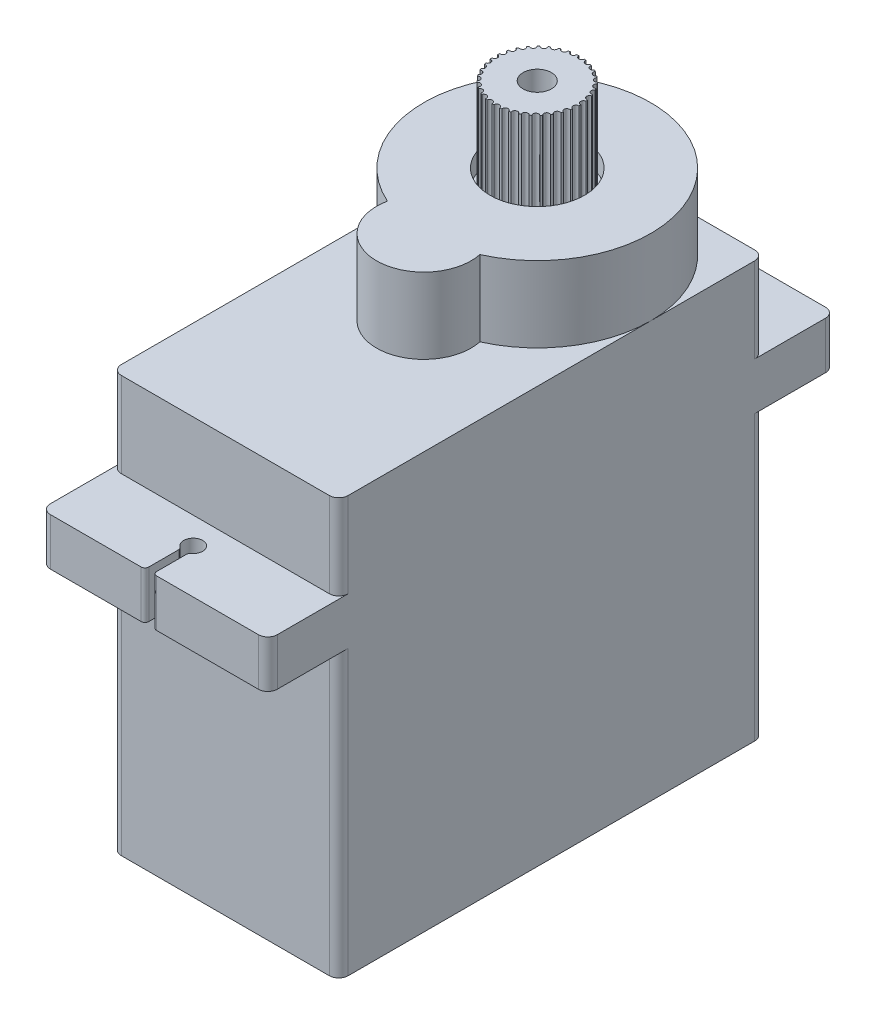
from build123d import *

# Parameters (mm, degrees)
Y_KSEKLIK_EKSTR_ZYON1_DEPTH  = 1
Y_KSEKLIK_EKSTR_ZYON2_DEPTH  = 5
IZIM3_W                      = 4
IZIM3_H                      = 1
KES_EKSTR_ZYON1_DEPTH        = 1
RADYUS1_R                    = 0.1
Y_KSEKLIK_EKSTR_ZYON4_DEPTH  = 9
Y_KSEKLIK_EKSTR_ZYON5_DEPTH  = 2.5
Y_KSEKLIK_EKSTR_ZYON6_DEPTH  = 3.5
Y_KSEKLIK_EKSTR_ZYON7_DEPTH  = 1
KES_EKSTR_ZYON2_DEPTH        = 1
Y_KSEKLIK_EKSTR_ZYON8_START  = 3
Y_KSEKLIK_EKSTR_ZYON8_DEPTH  = 3
RADYUS2_R                    = 0.5
Y_KSEKLIK_EKSTR_ZYON9_START  = 1
Y_KSEKLIK_EKSTR_ZYON9_DEPTH  = 1
IZIM11_R                     = 2.5
KES_EKSTR_ZYON3_DEPTH        = 10
IZIM15_R                     = 0.25
Y_KSEKLIK_EKSTR_ZYON12_DEPTH = 11
IZIM19_R                     = 2.25
Y_KSEKLIK_EKSTR_ZYON17_DEPTH = 5
IZIM20_R                     = 4.75
Y_KSEKLIK_EKSTR_ZYON18_DEPTH = 3
IZIM21_R                     = 0.75
KES_EKSTR_ZYON5_DEPTH        = 10
IZIM22_R                     = 0.5
Y_KSEKLIK_EKSTR_ZYON19_DEPTH = 5
IZIM23_R                     = 4
Y_KSEKLIK_EKSTR_ZYON20_DEPTH = 2
IZIM24_R                     = 0.75
Y_KSEKLIK_EKSTR_ZYON21_DEPTH = 7
IZIM25_R                     = 3.5
Y_KSEKLIK_EKSTR_ZYON22_DEPTH = 1
IZIM26_R                     = 4.5
Y_KSEKLIK_EKSTR_ZYON23_DEPTH = 1
KES_EKSTR_ZYON7_DEPTH        = 30
Y_KSEKLIK_EKSTR_ZYON33_DEPTH = 1
Y_KSEKLIK_EKSTR_ZYON34_DEPTH = 14
IZIM37_W                     = 8
IZIM37_H                     = 6
Y_KSEKLIK_EKSTR_ZYON36_DEPTH = 1
IZIM39_W                     = 4
IZIM39_H                     = 1
Y_KSEKLIK_EKSTR_ZYON37_DEPTH = 0.1
IZIM40_R                     = 0.4
Y_KSEKLIK_EKSTR_ZYON38_DEPTH = 2
IZIM41_R                     = 0.15
KES_EKSTR_ZYON8_DEPTH        = 5


with BuildPart() as part:
    # Çizim1 → Yükseklik-Ekstrüzyon1 (new body)
    with BuildSketch(Plane(origin=(0, 0, 0), x_dir=(1, 0, 0), z_dir=(0, 1, 0))):
        with BuildLine():
            Line((-5.5, 11.25), (5.5, 11.25))
            ThreePointArc((5.5, 11.25), (5.853553391, 11.103553391), (6, 10.75))
            Line((6, 10.75), (6, -10.75))
            ThreePointArc((6, -10.75), (5.853553391, -11.103553391), (5.5, -11.25))
            Line((5.5, -11.25), (-5.5, -11.25))
            ThreePointArc((-5.5, -11.25), (-5.853553391, -11.103553391), (-6, -10.75))
            Line((-6, -10.75), (-6, 10.75))
            ThreePointArc((-6, 10.75), (-5.853553391, 11.103553391), (-5.5, 11.25))
        make_face()
    extrude(amount=Y_KSEKLIK_EKSTR_ZYON1_DEPTH)

    # Çizim2 → Yükseklik-Ekstrüzyon2 (add)
    with BuildSketch(Plane(origin=(0, 1, 0), x_dir=(1, 0, 0), z_dir=(0, 1, 0))):
        with BuildLine():
            Line((-5.5, 11.25), (5.5, 11.25))
            ThreePointArc((5.5, 11.25), (5.853553391, 11.103553391), (6, 10.75))
            Line((6, 10.75), (6, -10.75))
            ThreePointArc((6, -10.75), (5.853553391, -11.103553391), (5.5, -11.25))
            Line((5.5, -11.25), (-5.5, -11.25))
            ThreePointArc((-5.5, -11.25), (-5.853553391, -11.103553391), (-6, -10.75))
            Line((-6, -10.75), (-6, 10.75))
            ThreePointArc((-6, 10.75), (-5.853553391, 11.103553391), (-5.5, 11.25))
        make_face()
        with BuildLine():
            Line((-5, 9.25), (-5, -9.25))
            ThreePointArc((-5, -9.25), (-4.292893219, -9.542893219), (-4, -10.25))
            Line((-4, -10.25), (4, -10.25))
            ThreePointArc((4, -10.25), (4.292893219, -9.542893219), (5, -9.25))
            Line((5, -9.25), (5, 9.25))
            ThreePointArc((5, 9.25), (4.292893219, 9.542893219), (4, 10.25))
            Line((4, 10.25), (-4, 10.25))
            ThreePointArc((-4, 10.25), (-4.292893219, 9.542893219), (-5, 9.25))
        make_face(mode=Mode.SUBTRACT)
    extrude(amount=Y_KSEKLIK_EKSTR_ZYON2_DEPTH)

    # Çizim3 → Kes-Ekstrüzyon1 (cut)
    with BuildSketch(Plane(origin=(0, 6, 0), x_dir=(1, 0, 0), z_dir=(0, 1, 0))):
        with Locations((0, -10.75)):
            Rectangle(IZIM3_W, IZIM3_H)
    extrude(amount=-KES_EKSTR_ZYON1_DEPTH, mode=Mode.SUBTRACT)

    # Radyus1
    radyus1_edges = [part.edges().sort_by_distance(p)[0] for p in [
        (2, 5, 10.75),
        (-2, 5, 10.75),
    ]]
    fillet(radyus1_edges, radius=RADYUS1_R)

    # Çizim4 → Yükseklik-Ekstrüzyon4 (add)
    with BuildSketch(Plane(origin=(0, 6, 0), x_dir=(1, 0, 0), z_dir=(0, 1, 0))):
        with BuildLine():
            Line((5.5, 11.25), (-5.5, 11.25))
            ThreePointArc((-5.5, 11.25), (-5.853553391, 11.103553391), (-6, 10.75))
            Line((-6, 10.75), (-6, -10.75))
            ThreePointArc((-6, -10.75), (-5.853553391, -11.103553391), (-5.5, -11.25))
            Line((-5.5, -11.25), (-2, -11.25))
            Line((-2, -11.25), (2, -11.25))
            Line((2, -11.25), (5.5, -11.25))
            ThreePointArc((5.5, -11.25), (5.853553391, -11.103553391), (6, -10.75))
            Line((6, -10.75), (6, 10.75))
            ThreePointArc((6, 10.75), (5.853553391, 11.103553391), (5.5, 11.25))
        make_face()
        with BuildLine():
            ThreePointArc((-5, 9.25), (-4.292893219, 9.542893219), (-4, 10.25))
            Line((-4, 10.25), (4, 10.25))
            ThreePointArc((4, 10.25), (4.292893219, 9.542893219), (5, 9.25))
            Line((5, 9.25), (5, -9.25))
            ThreePointArc((5, -9.25), (4.292893219, -9.542893219), (4, -10.25))
            Line((4, -10.25), (2, -10.25))
            Line((2, -10.25), (-2, -10.25))
            Line((-2, -10.25), (-4, -10.25))
            ThreePointArc((-4, -10.25), (-4.292893219, -9.542893219), (-5, -9.25))
            Line((-5, -9.25), (-5, 9.25))
        make_face(mode=Mode.SUBTRACT)
    extrude(amount=Y_KSEKLIK_EKSTR_ZYON4_DEPTH)

    # Çizim6 → Yükseklik-Ekstrüzyon5 (add)
    with BuildSketch(Plane(origin=(0, 15, 0), x_dir=(1, 0, 0), z_dir=(0, 1, 0))):
        with BuildLine():
            Line((-5.5, 15), (-0.7, 15))
            ThreePointArc((-0.7, 15), (-0.558578644, 14.941421356), (-0.5, 14.8))
            Line((-0.5, 14.8), (-0.5, 13.224679434))
            ThreePointArc((-0.5, 13.224679434), (-0.522048696, 13.133392342), (-0.583333333, 13.062232862))
            ThreePointArc((-0.583333333, 13.062232862), (-0.291666667, 12.156116431), (0, 13.062232862))
            ThreePointArc((0, 13.062232862), (-0.061284638, 13.133392342), (-0.083333333, 13.224679434))
            Line((-0.083333333, 13.224679434), (-0.083333333, 14.8))
            ThreePointArc((-0.083333333, 14.8), (-0.02475469, 14.941421356), (0.116666667, 15))
            Line((0.116666667, 15), (5.5, 15))
            ThreePointArc((5.5, 15), (5.853553391, 14.853553391), (6, 14.5))
            Line((6, 14.5), (6, -14.5))
            ThreePointArc((6, -14.5), (5.853553391, -14.853553391), (5.5, -15))
            Line((5.5, -15), (0.116666667, -15))
            ThreePointArc((0.116666667, -15), (-0.02475469, -14.941421356), (-0.083333333, -14.8))
            Line((-0.083333333, -14.8), (-0.083333333, -13.224679434))
            ThreePointArc((-0.083333333, -13.224679434), (-0.061284638, -13.133392342), (0, -13.062232862))
            ThreePointArc((0, -13.062232862), (-0.291666667, -12.156116431), (-0.583333333, -13.062232862))
            ThreePointArc((-0.583333333, -13.062232862), (-0.522048696, -13.133392342), (-0.5, -13.224679434))
            Line((-0.5, -13.224679434), (-0.5, -14.8))
            ThreePointArc((-0.5, -14.8), (-0.558578644, -14.941421356), (-0.7, -15))
            Line((-0.7, -15), (-5.5, -15))
            ThreePointArc((-5.5, -15), (-5.853553391, -14.853553391), (-6, -14.5))
            Line((-6, -14.5), (-6, 14.5))
            ThreePointArc((-6, 14.5), (-5.853553391, 14.853553391), (-5.5, 15))
        make_face()
        with BuildLine():
            Line((-4, 10.25), (4, 10.25))
            ThreePointArc((4, 10.25), (4.292893219, 9.542893219), (5, 9.25))
            Line((5, 9.25), (5, -9.25))
            ThreePointArc((5, -9.25), (4.324856337, -9.512313729), (4.003911578, -10.161637931))
            Line((4.003911578, -10.161637931), (-4.003911578, -10.161637931))
            ThreePointArc((-4.003911578, -10.161637931), (-4.324856337, -9.512313729), (-5, -9.25))
            Line((-5, -9.25), (-5, 9.25))
            ThreePointArc((-5, 9.25), (-4.292893219, 9.542893219), (-4, 10.25))
        make_face(mode=Mode.SUBTRACT)
    extrude(amount=Y_KSEKLIK_EKSTR_ZYON5_DEPTH)

    # Çizim7 → Yükseklik-Ekstrüzyon6 (add)
    with BuildSketch(Plane(origin=(0, 17.5, 0), x_dir=(1, 0, 0), z_dir=(0, 1, 0))):
        with BuildLine():
            Line((5.5, 11.25), (-5.5, 11.25))
            ThreePointArc((-5.5, 11.25), (-5.853553391, 11.103553391), (-6, 10.75))
            Line((-6, 10.75), (-6, -10.75))
            ThreePointArc((-6, -10.75), (-5.853553391, -11.103553391), (-5.5, -11.25))
            Line((-5.5, -11.25), (5.5, -11.25))
            ThreePointArc((5.5, -11.25), (5.853553391, -11.103553391), (6, -10.75))
            Line((6, -10.75), (6, 10.75))
            ThreePointArc((6, 10.75), (5.853553391, 11.103553391), (5.5, 11.25))
        make_face()
        with BuildLine():
            Line((-5, -9.25), (-5, 9.25))
            ThreePointArc((-5, 9.25), (-4.292893219, 9.542893219), (-4, 10.25))
            Line((-4, 10.25), (4, 10.25))
            ThreePointArc((4, 10.25), (4.292893219, 9.542893219), (5, 9.25))
            Line((5, 9.25), (5, -9.25))
            ThreePointArc((5, -9.25), (4.324856337, -9.512313729), (4.003911578, -10.161637931))
            ThreePointArc((4.003911578, -10.161637931), (4.000978373, -10.205775698), (4, -10.25))
            Line((4, -10.25), (-4, -10.25))
            ThreePointArc((-4, -10.25), (-4.000978373, -10.205775698), (-4.003911578, -10.161637931))
            ThreePointArc((-4.003911578, -10.161637931), (-4.324856337, -9.512313729), (-5, -9.25))
        make_face(mode=Mode.SUBTRACT)
    extrude(amount=Y_KSEKLIK_EKSTR_ZYON6_DEPTH)

    # Çizim8 → Yükseklik-Ekstrüzyon7 (add)
    with BuildSketch(Plane(origin=(0, 21, 0), x_dir=(1, 0, 0), z_dir=(0, 1, 0))):
        with BuildLine():
            Line((-5.5, 11.25), (5.5, 11.25))
            ThreePointArc((5.5, 11.25), (5.853553391, 11.103553391), (6, 10.75))
            Line((6, 10.75), (6, -10.75))
            ThreePointArc((6, -10.75), (5.853553391, -11.103553391), (5.5, -11.25))
            Line((5.5, -11.25), (-5.5, -11.25))
            ThreePointArc((-5.5, -11.25), (-5.853553391, -11.103553391), (-6, -10.75))
            Line((-6, -10.75), (-6, 10.75))
            ThreePointArc((-6, 10.75), (-5.853553391, 11.103553391), (-5.5, 11.25))
        make_face()
    extrude(amount=Y_KSEKLIK_EKSTR_ZYON7_DEPTH)

    # Çizim9 → Kes-Ekstrüzyon2 (cut)
    with BuildSketch(Plane(origin=(0, 22, 0), x_dir=(1, 0, 0), z_dir=(0, 1, 0))):
        with BuildLine():
            ThreePointArc((1.015291078, 0.354166667), (0, 10.25), (-1.015291078, 0.354166667))
            ThreePointArc((-1.015291078, 0.354166667), (0, -2.25), (1.015291078, 0.354166667))
        make_face()
    extrude(amount=-KES_EKSTR_ZYON2_DEPTH, mode=Mode.SUBTRACT)

    # Çizim9<3> → Yükseklik-Ekstrüzyon8 (add)
    with BuildSketch(Plane(origin=(0, 22, 0), x_dir=(1, 0, 0), z_dir=(0, 1, 0)).offset(Y_KSEKLIK_EKSTR_ZYON8_START)):
        with BuildLine():
            ThreePointArc((2.445144707, -0.229166667), (0, 11.25), (-2.445144707, -0.229166667))
            ThreePointArc((-2.445144707, -0.229166667), (0, -3.25), (2.445144707, -0.229166667))
        make_face()
        with BuildLine():
            ThreePointArc((1.015291078, 0.354166667), (0, 10.25), (-1.015291078, 0.354166667))
            ThreePointArc((-1.015291078, 0.354166667), (0, -2.25), (1.015291078, 0.354166667))
        make_face(mode=Mode.SUBTRACT)
    extrude(amount=-Y_KSEKLIK_EKSTR_ZYON8_DEPTH)

    # Radyus2
    radyus2_edges = [part.edges().sort_by_distance(p)[0] for p in [
        (1.015291078, 23, -0.354166667),
        (-1.015291078, 23, -0.354166667),
    ]]
    fillet(radyus2_edges, radius=RADYUS2_R)

    # Çizim10 → Yükseklik-Ekstrüzyon9 (add)
    with BuildSketch(Plane(origin=(0, 25, 0), x_dir=(1, 0, 0), z_dir=(0, 1, 0)).offset(Y_KSEKLIK_EKSTR_ZYON9_START)):
        with BuildLine():
            ThreePointArc((2.445144707, -0.229166667), (0, 11.25), (-2.445144707, -0.229166667))
            ThreePointArc((-2.445144707, -0.229166667), (0, -3.25), (2.445144707, -0.229166667))
        make_face()
    extrude(amount=-Y_KSEKLIK_EKSTR_ZYON9_DEPTH)

    # Çizim11 → Kes-Ekstrüzyon3 (cut)
    with BuildSketch(Plane(origin=(0, 26, 0), x_dir=(1, 0, 0), z_dir=(0, 1, 0))):
        with Locations((0, 5.25)):
            Circle(IZIM11_R)
    extrude(amount=-KES_EKSTR_ZYON3_DEPTH, mode=Mode.SUBTRACT)

    # Çizim15 → Yükseklik-Ekstrüzyon12 (add)
    with BuildSketch(Plane(origin=(0, 26, 0), x_dir=(1, 0, 0), z_dir=(0, 1, 0))):
        with Locations((0, -0.75)):
            Circle(IZIM15_R)
    extrude(amount=-Y_KSEKLIK_EKSTR_ZYON12_DEPTH)



with BuildPart() as body_2:
    # Çizim19 → Yükseklik-Ekstrüzyon17 (new body)
    with BuildSketch(Plane(origin=(0, 30, 0), x_dir=(1, 0, 0), z_dir=(0, 1, 0))):
        with Locations((0, 5.25)):
            Circle(IZIM19_R)
    extrude(amount=-Y_KSEKLIK_EKSTR_ZYON17_DEPTH)


with BuildPart() as part_1:
    add(part.part)

    add(body_2.part)  # Yükseklik-Ekstrüzyon18 merges body 2
    # Çizim20 → Yükseklik-Ekstrüzyon18 (add)
    with BuildSketch(Plane.XZ.offset(-25)):
        with Locations((0, -5.25)):
            Circle(IZIM20_R)
    extrude(amount=Y_KSEKLIK_EKSTR_ZYON18_DEPTH)

    # Çizim21 → Kes-Ekstrüzyon5 (cut)
    with BuildSketch(Plane(origin=(0, 30, 0), x_dir=(1, 0, 0), z_dir=(0, 1, 0))):
        with Locations((0, 5.25)):
            Circle(IZIM21_R)
    extrude(amount=-KES_EKSTR_ZYON5_DEPTH, mode=Mode.SUBTRACT)

    # Çizim22 → Yükseklik-Ekstrüzyon19 (add)
    with BuildSketch(Plane(origin=(0, 25.5, 0), x_dir=(1, 0, 0), z_dir=(0, 1, 0))):
        with Locations((0, -0.75)):
            Circle(IZIM22_R)
    extrude(amount=-Y_KSEKLIK_EKSTR_ZYON19_DEPTH)

    # Çizim23 → Yükseklik-Ekstrüzyon20 (add)
    with BuildSketch(Plane.XZ.offset(-20.5)):
        with Locations((0, 0.75)):
            Circle(IZIM23_R)
    extrude(amount=Y_KSEKLIK_EKSTR_ZYON20_DEPTH)

    # Çizim26 → Yükseklik-Ekstrüzyon23 (add)
    with BuildSketch(Plane(origin=(0, 17.5, 0), x_dir=(-1, 0, 0), z_dir=(0, -1, 0))):
        with Locations((0, -0.75)):
            Circle(IZIM26_R)
    extrude(amount=Y_KSEKLIK_EKSTR_ZYON23_DEPTH)

    # Çizim32 → Kes-Ekstrüzyon7 (cut)
    with BuildSketch(Plane(origin=(0, 0, 10.25), x_dir=(-1, 0, 0), z_dir=(0, 0, -1))):
        with BuildLine():
            Line((2, 6), (-2, 6))
            Line((-2, 6), (-2, 5.1))
            ThreePointArc((-2, 5.1), (-1.970710678, 5.029289322), (-1.9, 5))
            Line((-1.9, 5), (1.9, 5))
            ThreePointArc((1.9, 5), (1.970710678, 5.029289322), (2, 5.1))
            Line((2, 5.1), (2, 6))
        make_face()
    extrude(amount=KES_EKSTR_ZYON7_DEPTH, mode=Mode.SUBTRACT)

    # Çizim33 → Yükseklik-Ekstrüzyon33 (add)
    with BuildSketch(Plane.XY.offset(11.25)):
        with BuildLine():
            Line((-2, 6), (2, 6))
            Line((2, 6), (2, 5.1))
            ThreePointArc((2, 5.1), (1.970710678, 5.029289322), (1.9, 5))
            Line((1.9, 5), (-1.9, 5))
            ThreePointArc((-1.9, 5), (-1.970710678, 5.029289322), (-2, 5.1))
            Line((-2, 5.1), (-2, 6))
        make_face()
    extrude(amount=-Y_KSEKLIK_EKSTR_ZYON33_DEPTH)

    # Çizim34 → Yükseklik-Ekstrüzyon34 (add)
    with BuildSketch(Plane(origin=(0, 1, 0), x_dir=(1, 0, 0), z_dir=(0, 1, 0))):
        with BuildLine():
            Line((-3, -3.25), (3, -3.25))
            ThreePointArc((3, -3.25), (3.707106781, -3.542893219), (4, -4.25))
            Line((4, -4.25), (4, -8.25))
            ThreePointArc((4, -8.25), (3.707106781, -8.957106781), (3, -9.25))
            Line((3, -9.25), (-3, -9.25))
            ThreePointArc((-3, -9.25), (-3.707106781, -8.957106781), (-4, -8.25))
            Line((-4, -8.25), (-4, -4.25))
            ThreePointArc((-4, -4.25), (-3.707106781, -3.542893219), (-3, -3.25))
        make_face()
    extrude(amount=Y_KSEKLIK_EKSTR_ZYON34_DEPTH)

    # Çizim37 → Yükseklik-Ekstrüzyon36 (add)
    with BuildSketch(Plane(origin=(0, 1, 0), x_dir=(-1, 0, 0), z_dir=(0, -1, 0))):
        with Locations((0, -6.25)):
            Rectangle(IZIM37_W, IZIM37_H)
    extrude(amount=-Y_KSEKLIK_EKSTR_ZYON36_DEPTH)

    # Çizim39 → Yükseklik-Ekstrüzyon37 (add)
    with BuildSketch(Plane(origin=(0, 0, -10.75), x_dir=(-1, 0, 0), z_dir=(0, 0, -1))):
        with Locations((0, 5.514566781)):
            Rectangle(IZIM39_W, IZIM39_H)
    extrude(amount=Y_KSEKLIK_EKSTR_ZYON37_DEPTH)

    # Çizim40 → Yükseklik-Ekstrüzyon38 (add)
    with BuildSketch(Plane(origin=(0, 0, -10.85), x_dir=(-1, 0, 0), z_dir=(0, 0, -1))):
        with Locations((0, 5.55)):
            Circle(IZIM40_R)
        with Locations((1, 5.55)):
            Circle(IZIM40_R)
        with Locations((-1, 5.55)):
            Circle(IZIM40_R)
    extrude(amount=Y_KSEKLIK_EKSTR_ZYON38_DEPTH)

    # Çizim41 → Kes-Ekstrüzyon8 (cut)
    with BuildSketch(Plane(origin=(0, 30, 0), x_dir=(1, 0, 0), z_dir=(0, 1, 0))):
        with Locations((-2.25, 5.25)):
            Circle(IZIM41_R)
        with Locations((-2.213841574, 5.651753013)):
            Circle(IZIM41_R)
        with Locations((-2.213841574, 4.848246987)):
            Circle(IZIM41_R)
        with Locations((-2.106528459, 6.040593354)):
            Circle(IZIM41_R)
        with Locations((-2.106528459, 4.459406646)):
            Circle(IZIM41_R)
        with Locations((-1.931509786, 6.404023374)):
            Circle(IZIM41_R)
        with Locations((-1.931509786, 4.095976626)):
            Circle(IZIM41_R)
        with Locations((-1.694410799, 6.730362133)):
            Circle(IZIM41_R)
        with Locations((-1.694410799, 3.769637867)):
            Circle(IZIM41_R)
        with Locations((-1.402852054, 7.009120836)):
            Circle(IZIM41_R)
        with Locations((-1.402852054, 3.490879164)):
            Circle(IZIM41_R)
        with Locations((-1.066204491, 7.231339947)):
            Circle(IZIM41_R)
        with Locations((-1.066204491, 3.268660053)):
            Circle(IZIM41_R)
        with Locations((-0.695288237, 7.389877162)):
            Circle(IZIM41_R)
        with Locations((-0.695288237, 3.110122838)):
            Circle(IZIM41_R)
        with Locations((-0.302024848, 7.479636964)):
            Circle(IZIM41_R)
        with Locations((-0.302024848, 3.020363036)):
            Circle(IZIM41_R)
        with Locations((0.100945868, 7.4977344)):
            Circle(IZIM41_R)
        with Locations((0.100945868, 3.0022656)):
            Circle(IZIM41_R)
        with Locations((0.500672101, 7.443587802)):
            Circle(IZIM41_R)
        with Locations((0.500672101, 3.056412198)):
            Circle(IZIM41_R)
        with Locations((0.884306321, 7.318937488)):
            Circle(IZIM41_R)
        with Locations((0.884306321, 3.181062512)):
            Circle(IZIM41_R)
        with Locations((1.239518208, 7.127789821)):
            Circle(IZIM41_R)
        with Locations((1.239518208, 3.372210179)):
            Circle(IZIM41_R)
        with Locations((1.55489096, 6.876288444)):
            Circle(IZIM41_R)
        with Locations((1.55489096, 3.623711556)):
            Circle(IZIM41_R)
        with Locations((1.820288237, 6.572516818)):
            Circle(IZIM41_R)
        with Locations((1.820288237, 3.927483182)):
            Circle(IZIM41_R)
        with Locations((2.027179953, 6.226238413)):
            Circle(IZIM41_R)
        with Locations((2.027179953, 4.273761587)):
            Circle(IZIM41_R)
        with Locations((2.168916437, 5.848582903)):
            Circle(IZIM41_R)
        with Locations((2.168916437, 4.651417097)):
            Circle(IZIM41_R)
        with Locations((2.240942161, 5.451688445)):
            Circle(IZIM41_R)
        with Locations((2.240942161, 5.048311555)):
            Circle(IZIM41_R)
    extrude(amount=-KES_EKSTR_ZYON8_DEPTH, mode=Mode.SUBTRACT)


with BuildPart() as body_2_2:
    # Çizim24 → Yükseklik-Ekstrüzyon21 (new body)
    with BuildSketch(Plane.XZ.offset(-22)):
        with Locations((0, -5.25)):
            Circle(IZIM24_R)
    extrude(amount=Y_KSEKLIK_EKSTR_ZYON21_DEPTH)

    # Çizim25 → Yükseklik-Ekstrüzyon22 (add)
    with BuildSketch(Plane(origin=(0, 19, 0), x_dir=(-1, 0, 0), z_dir=(0, -1, 0))):
        with Locations((0, 5.25)):
            Circle(IZIM25_R)
    extrude(amount=Y_KSEKLIK_EKSTR_ZYON22_DEPTH)


solid = Compound([part_1.part, body_2_2.part])
